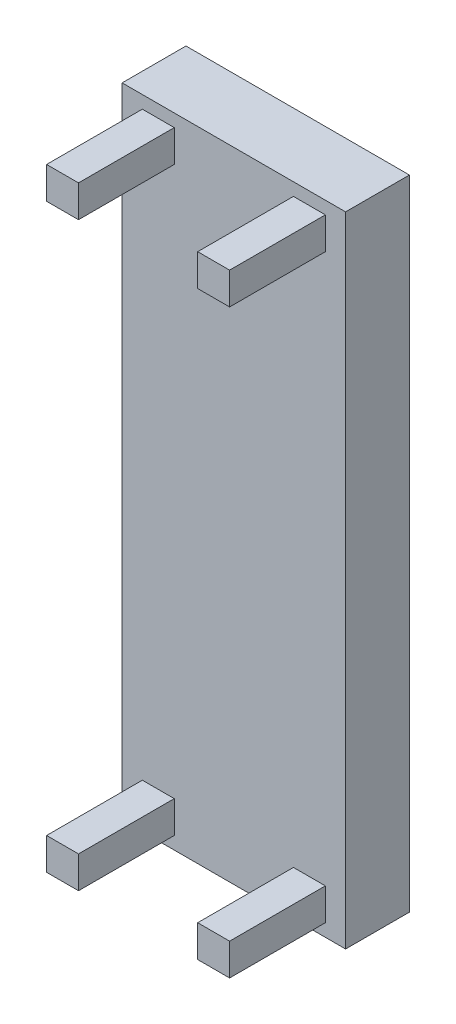
from build123d import *

# Parameters (mm, degrees)
SKETCH_1_W      = 700
SKETCH_1_H      = 2000
EXTRUDE_1_DEPTH = 200
SKETCH_2_W      = 100
SKETCH_2_H      = 100
EXTRUDE_2_DEPTH = 300


with BuildPart() as part:
    # 草图1 → 凸台-拉伸1 (new body)
    with BuildSketch(Plane.XY):
        Rectangle(SKETCH_1_W, SKETCH_1_H)
    extrude(amount=EXTRUDE_1_DEPTH)

    # 草图2 → 凸台-拉伸2 (add)
    with BuildSketch(Plane.XY.offset(200)):
        with Locations((-236.693905306, 910.285310824)):
            Rectangle(SKETCH_2_W, SKETCH_2_H)
        with Locations((236.693905306, 910.285310824)):
            Rectangle(SKETCH_2_W, SKETCH_2_H)
        with Locations((236.693905306, -910.285310824)):
            Rectangle(SKETCH_2_W, SKETCH_2_H)
        with Locations((-236.693905306, -910.285310824)):
            Rectangle(SKETCH_2_W, SKETCH_2_H)
    extrude(amount=EXTRUDE_2_DEPTH)


solid = part.part
